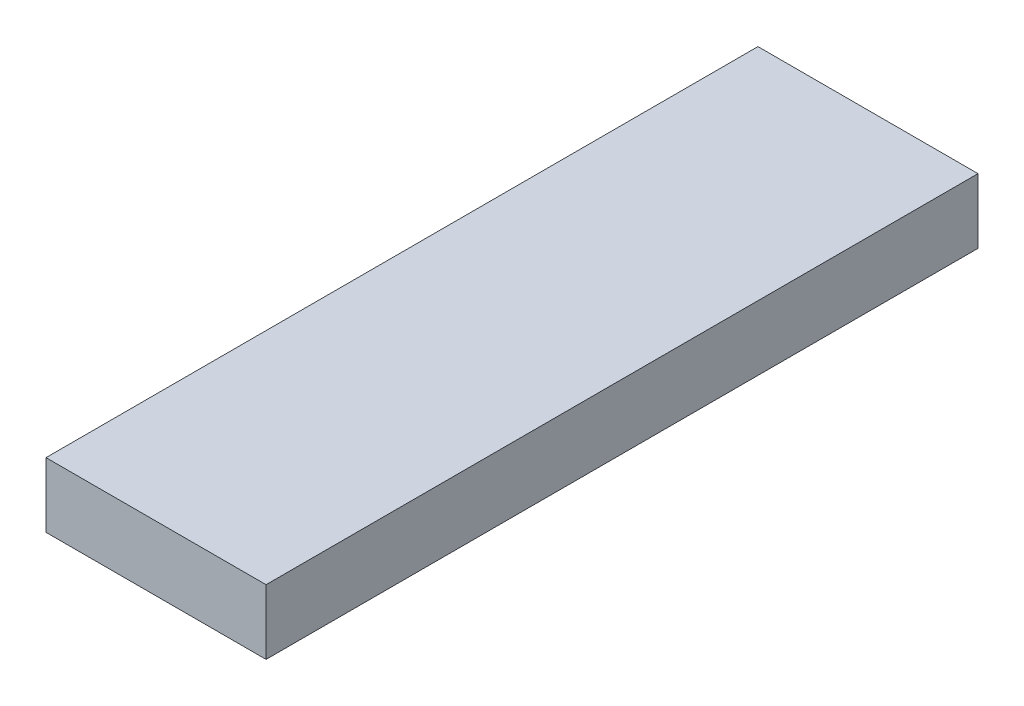
from build123d import *

# Parameters (mm, degrees)
SKETCH2_W           = 34
SKETCH2_H           = 55
BOSS_EXTRUDE1_DEPTH = 10
SKETCH1_R           = 3.15
CUT_EXTRUDE1_DEPTH  = 5


with BuildPart() as part:
    # Sketch2 → Boss-Extrude1 (new body)
    with BuildSketch(Plane(origin=(0, 0, 0), x_dir=(1, 0, 0), z_dir=(0, 1, 0))):
        with Locations((12.4, -23.06737043)):
            Rectangle(SKETCH2_W, SKETCH2_H)
    extrude(amount=BOSS_EXTRUDE1_DEPTH)

    # Sketch1 → Cut-Extrude1 (cut)
    with BuildSketch(Plane(origin=(0, 0, 0), x_dir=(1, 0, 0), z_dir=(0, 1, 0))):
        Circle(SKETCH1_R)
        with Locations((24.8, 0)):
            Circle(SKETCH1_R)
        with Locations((0, -24.8)):
            Circle(SKETCH1_R)
        with Locations((24.8, -24.8)):
            Circle(SKETCH1_R)
    extrude(amount=CUT_EXTRUDE1_DEPTH, mode=Mode.SUBTRACT)

    # Mirror1: part across plane


with BuildPart() as part_1:
    add(part.part)
    add(part.part.mirror(Plane(origin=(-4.6, 10, 50.56737043), x_dir=(1, 0, 0), z_dir=(0, 0, -1))))


solid = part_1.part
